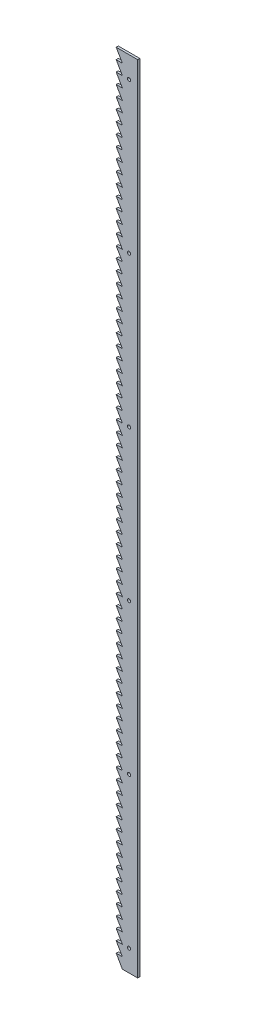
from build123d import *

# Parameters (mm, degrees)
SKETCH1_R           = 1.5
BOSS_EXTRUDE1_DEPTH = 2


with BuildPart() as part:
    # Sketch1 → Boss-Extrude1 (new body)
    with BuildSketch(Plane.XY):
        Polygon((0, 370), (0, -370), (-14.226497308, -370), (-20, -360), (-14.226497308, -360), (-20, -350), (-14.226497308, -350), (-20, -340), (-14.226497308, -340), (-20, -330), (-14.226497308, -330), (-20, -320), (-14.226497308, -320), (-20, -310), (-14.226497308, -310), (-20, -300), (-14.226497308, -300), (-20, -290), (-14.226497308, -290), (-20, -280), (-14.226497308, -280), (-20, -270), (-14.226497308, -270), (-20, -260), (-14.226497308, -260), (-20, -250), (-14.226497308, -250), (-20, -240), (-14.226497308, -240), (-20, -230), (-14.226497308, -230), (-20, -220), (-14.226497308, -220), (-20, -210), (-14.226497308, -210), (-20, -200), (-14.226497308, -200), (-20, -190), (-14.226497308, -190), (-20, -180), (-14.226497308, -180), (-20, -170), (-14.226497308, -170), (-20, -160), (-14.226497308, -160), (-20, -150), (-14.226497308, -150), (-20, -140), (-14.226497308, -140), (-20, -130), (-14.226497308, -130), (-20, -120), (-14.226497308, -120), (-20, -110), (-14.226497308, -110), (-20, -100), (-14.226497308, -100), (-20, -90), (-14.226497308, -90), (-20, -80), (-14.226497308, -80), (-20, -70), (-14.226497308, -70), (-20, -60), (-14.226497308, -60), (-20, -50), (-14.226497308, -50), (-20, -40), (-14.226497308, -40), (-20, -30), (-14.226497308, -30), (-20, -20), (-14.226497308, -20), (-20, -10), (-14.226497308, -10), (-20, 0), (-14.226497308, 0), (-20, 10), (-14.226497308, 10), (-20, 20), (-14.226497308, 20), (-20, 30), (-14.226497308, 30), (-20, 40), (-14.226497308, 40), (-20, 50), (-14.226497308, 50), (-20, 60), (-14.226497308, 60), (-20, 70), (-14.226497308, 70), (-20, 80), (-14.226497308, 80), (-20, 90), (-14.226497308, 90), (-20, 100), (-14.226497308, 100), (-20, 110), (-14.226497308, 110), (-20, 120), (-14.226497308, 120), (-20, 130), (-14.226497308, 130), (-20, 140), (-14.226497308, 140), (-20, 150), (-14.226497308, 150), (-20, 160), (-14.226497308, 160), (-20, 170), (-14.226497308, 170), (-20, 180), (-14.226497308, 180), (-20, 190), (-14.226497308, 190), (-20, 200), (-14.226497308, 200), (-20, 210), (-14.226497308, 210), (-20, 220), (-14.226497308, 220), (-20, 230), (-14.226497308, 230), (-20, 240), (-14.226497308, 240), (-20, 250), (-14.226497308, 250), (-20, 260), (-14.226497308, 260), (-20, 270), (-14.226497308, 270), (-20, 280), (-14.226497308, 280), (-20, 290), (-14.226497308, 290), (-20, 300), (-14.226497308, 300), (-20, 310), (-14.226497308, 310), (-20, 320), (-14.226497308, 320), (-20, 330), (-14.226497308, 330), (-20, 340), (-14.226497308, 340), (-20, 350), (-14.226497308, 350), (-20, 360), (-14.226497308, 360), (-20, 370), align=None)
        with Locations((-8, 350)):
            Circle(SKETCH1_R, mode=Mode.SUBTRACT)
        with Locations((-8, 210)):
            Circle(SKETCH1_R, mode=Mode.SUBTRACT)
        with Locations((-8, 70)):
            Circle(SKETCH1_R, mode=Mode.SUBTRACT)
        with Locations((-8, -70)):
            Circle(SKETCH1_R, mode=Mode.SUBTRACT)
        with Locations((-8, -210)):
            Circle(SKETCH1_R, mode=Mode.SUBTRACT)
        with Locations((-8, -350)):
            Circle(SKETCH1_R, mode=Mode.SUBTRACT)
    extrude(amount=BOSS_EXTRUDE1_DEPTH)


solid = part.part
